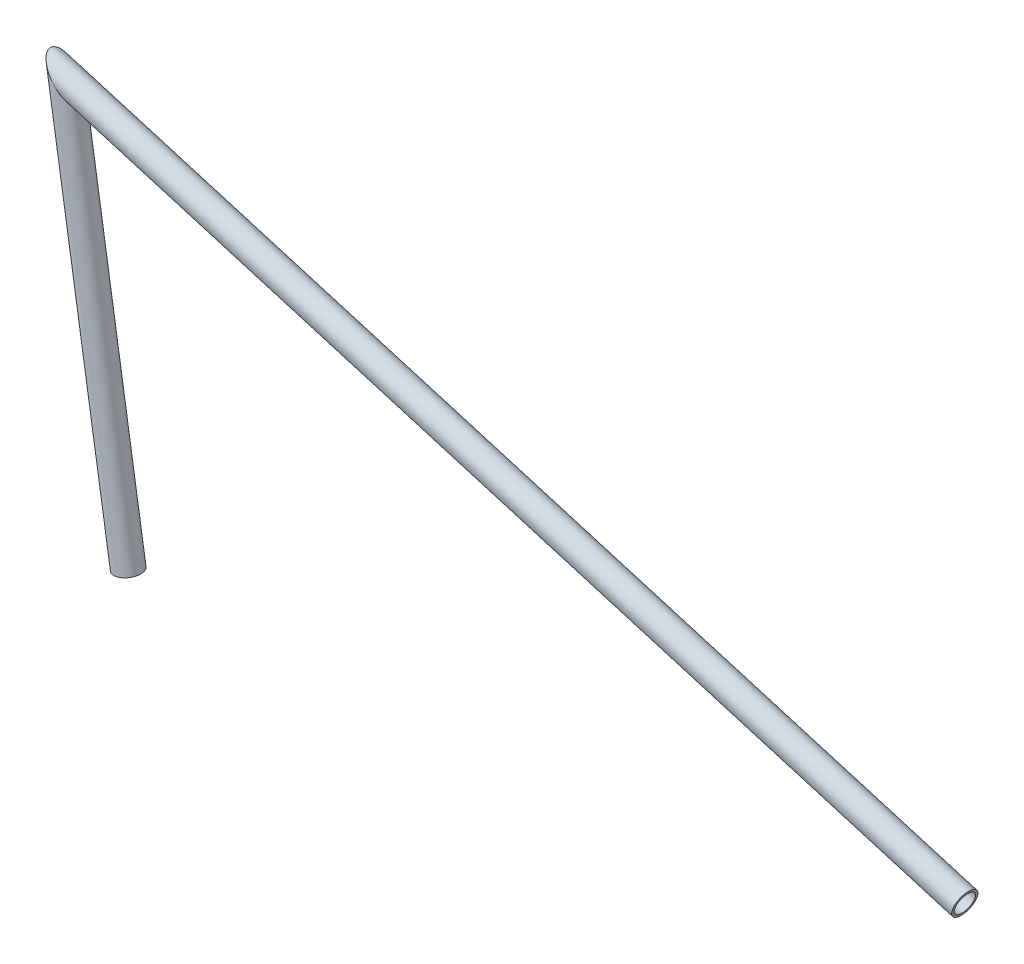
from build123d import *

# Parameters (mm, degrees)
SKETCH11_R                 = 7.9375
SKETCH11_R_2               = 6.4643
STRUCTURAL_MEMBER1_DEPTH   = 269.152773911
SKETCH11_ON_SEGMENT_2_R    = 7.9375
SKETCH11_ON_SEGMENT_2_R_2  = 6.4643
STRUCTURAL_MEMBER1_2_DEPTH = 605.722096433


with BuildPart() as part:
    # Sketch11 → Structural Member1 (new body)
    with BuildSketch(Plane(origin=(38.9, -247.342302395, 0), x_dir=(-0.9878575646087404, -0.15536226068543246, 0), z_dir=(-0.15536226068543246, 0.9878575646087404, 0))):
        Circle(SKETCH11_R)
        Circle(SKETCH11_R_2, mode=Mode.SUBTRACT)
    extrude(amount=STRUCTURAL_MEMBER1_DEPTH)

    # Structural Member1 mitre 1
    split(bisect_by=Plane(origin=(0, 0, 0), x_dir=(0.658927354, -0.752206582, 0), z_dir=(-0.752206582, -0.658927354, 0)), keep=Keep.TOP)


with BuildPart() as body_2:
    # Sketch11 on segment 2 (carried to segment 2) → Structural Member1 2 (new body)
    with BuildSketch(Plane(origin=(-17.9971088, 5.331523223, 0), x_dir=(0.284041633, 0.958811948, 0), z_dir=(0.958811948, -0.284041633, 0))):
        Circle(SKETCH11_ON_SEGMENT_2_R)
        Circle(SKETCH11_ON_SEGMENT_2_R_2, mode=Mode.SUBTRACT)
    extrude(amount=STRUCTURAL_MEMBER1_2_DEPTH)

    # Structural Member1 2 mitre 1
    split(bisect_by=Plane(origin=(0, 0, 0), x_dir=(-0.658927354, 0.752206582, 0), z_dir=(0.752206582, 0.658927354, 0)), keep=Keep.TOP)


solid = Compound([part.part, body_2.part])
